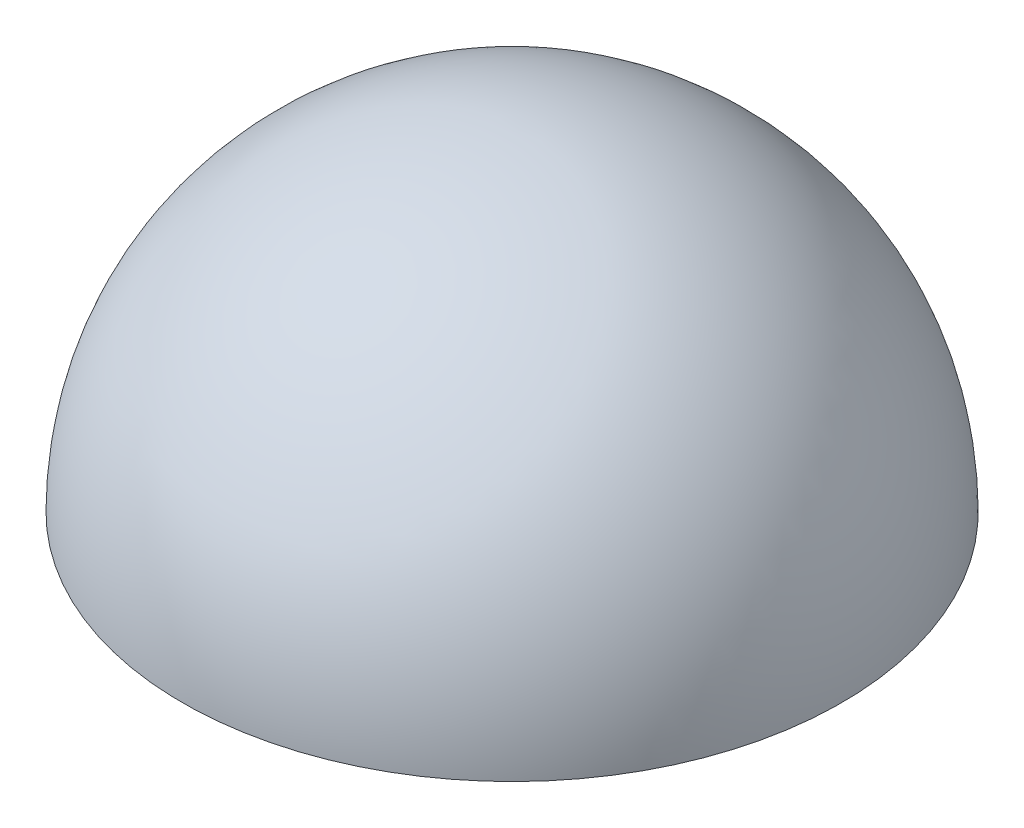
from build123d import *

# Parameters (mm, degrees)
REVOLVE2_ANGLE = 180


with BuildPart() as part:
    # Sketch1 → Revolve2 (revolve)
    with BuildSketch(Plane(origin=(0, 0, 0), x_dir=(1, 0, 0), z_dir=(0, 1, 0))):
        with BuildLine():
            ThreePointArc((-30, 0), (0, 30), (30, 0))
            Line((30, 0), (31.5, 0))
            ThreePointArc((31.5, 0), (0, 31.5), (-31.5, 0))
            Line((-31.5, 0), (-30, 0))
        make_face()
    revolve(axis=Axis((-31.5, 0, 0), (1, 0, 0)), revolution_arc=REVOLVE2_ANGLE)


solid = part.part
